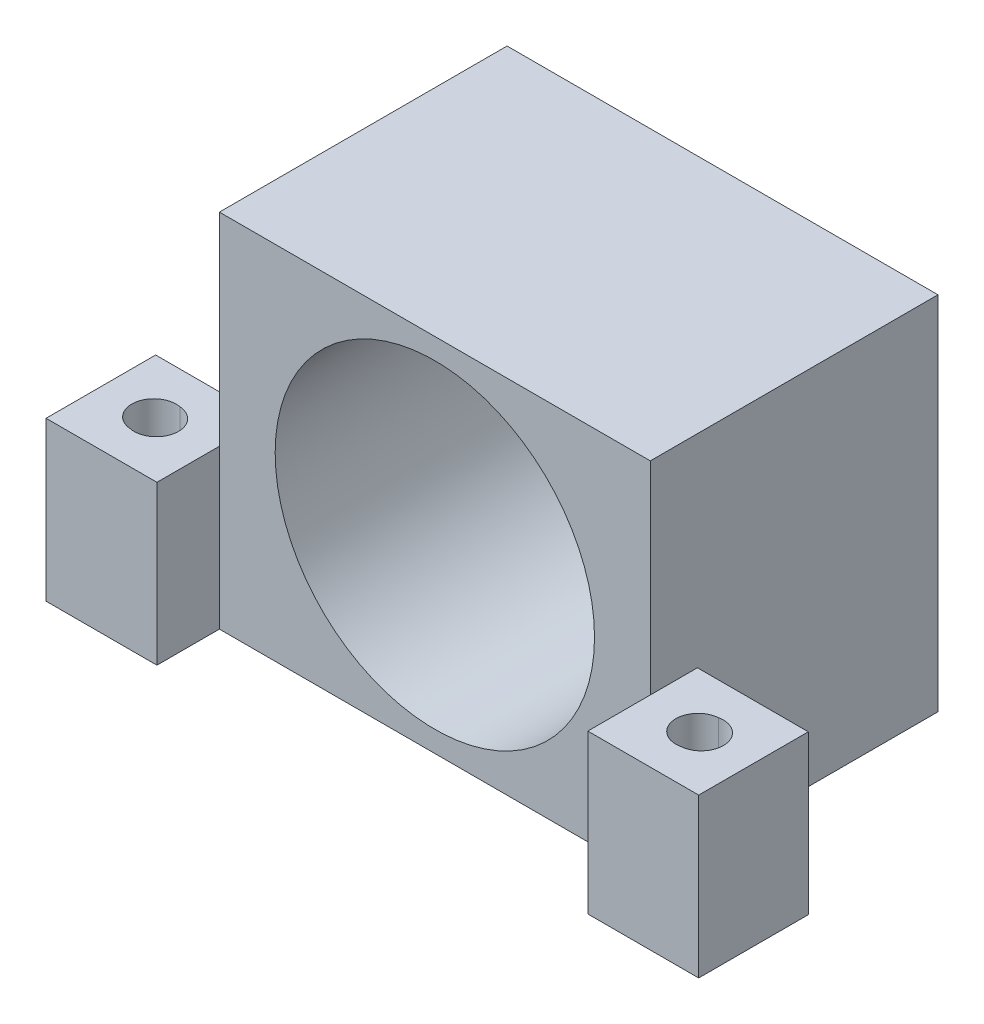
from build123d import *

# Parameters (mm, degrees)
SKETCH1_W                = 34
SKETCH1_H                = 28.5
BOSS_EXTRUDE1_DEPTH      = 22.7
SKETCH3_R                = 12.6
CUT_EXTRUDE1_DEPTH       = 19
SKETCH5_R                = 1.625
SKETCH5_R_2              = 3.75
CUT_EXTRUDE2_DEPTH       = 30.207233693
BOSS_EXTRUDE2_DEPTH      = 4.93
BOSS_EXTRUDE2_DEPTH_BACK = 3.72
SKETCH7_W                = 8.75
SKETCH7_H                = 12.5
SKETCH8_R                = 1.75
CUT_EXTRUDE3_DEPTH       = 42.018037496
SKETCH9_R                = 3.25
CUT_EXTRUDE4_DEPTH       = 3.175
SKETCH14_R               = 1.75
CUT_EXTRUDE8_DEPTH       = 50


with BuildPart() as part:
    # Sketch1 → Boss-Extrude1 (new body)
    with BuildSketch(Plane.XY):
        Rectangle(SKETCH1_W, SKETCH1_H)
    extrude(amount=BOSS_EXTRUDE1_DEPTH)

    # Sketch3 → Cut-Extrude1 (cut)
    with BuildSketch(Plane.XY.offset(22.7)):
        Circle(SKETCH3_R)
    extrude(amount=-CUT_EXTRUDE1_DEPTH, mode=Mode.SUBTRACT)

    # Sketch5 → Cut-Extrude2 (cut, through all)
    with BuildSketch(Plane.XY.offset(3.7)):
        with Locations((6.01040764, 6.01040764)):
            Circle(SKETCH5_R)
        with Locations((-6.01040764, 6.01040764)):
            Circle(SKETCH5_R)
        with Locations((6.01040764, -6.01040764)):
            Circle(SKETCH5_R)
        with Locations((-6.01040764, -6.01040764)):
            Circle(SKETCH5_R)
        Circle(SKETCH5_R_2)
    extrude(amount=-CUT_EXTRUDE2_DEPTH, mode=Mode.SUBTRACT)

    # Sketch7 → Boss-Extrude2 (add, two sides: drawn at the far end of the back side and taken through both)
    with BuildSketch(Plane.XY.offset(22.7).offset(-BOSS_EXTRUDE2_DEPTH_BACK)):
        with Locations((-21.375, -8)):
            Rectangle(SKETCH7_W, SKETCH7_H)
        with Locations((21.375, -8)):
            Rectangle(SKETCH7_W, SKETCH7_H)
    extrude(amount=BOSS_EXTRUDE2_DEPTH + BOSS_EXTRUDE2_DEPTH_BACK)

    # Sketch8 → Cut-Extrude3 (cut, through all)
    with BuildSketch(Plane(origin=(0, -1.75, 0), x_dir=(1, 0, 0), z_dir=(0, 1, 0))):
        with Locations(Location((21.375, -23.305, 0), (0, 0, 180))):
            Circle(SKETCH8_R)
        with Locations(Location((-21.375, -23.305, 0), (0, 0, 180))):
            Circle(SKETCH8_R)
    extrude(amount=-CUT_EXTRUDE3_DEPTH, mode=Mode.SUBTRACT)

    # Sketch9 → Cut-Extrude4 (cut)
    with BuildSketch(Plane.XZ.offset(14.25)):
        with Locations((-21.375, 23.305)):
            Circle(SKETCH9_R)
        with Locations((21.375, 23.305)):
            Circle(SKETCH9_R)
    extrude(amount=-CUT_EXTRUDE4_DEPTH, mode=Mode.SUBTRACT)

    # Cut-Extrude5 cone 1 section (through the dimple's axis) → Cut-Extrude5 (revolve, cut)
    with BuildSketch(Plane(origin=(-6.01040764, 6.01040764, 0), x_dir=(0, 1, 0), z_dir=(1, 0, 0))):
        Polygon((0, 0), (2.8, 0), (0, 2.8), align=None)
    revolve(axis=Axis((-6.01040764, 6.01040764, 0), (0, 0, 1)), mode=Mode.SUBTRACT)

    # Cut-Extrude5 cone 2 section (through the dimple's axis) → Cut-Extrude5 cone 2 (revolve, cut)
    with BuildSketch(Plane(origin=(-6.01040764, -6.01040764, 0), x_dir=(0, 1, 0), z_dir=(1, 0, 0))):
        Polygon((0, 0), (2.8, 0), (0, 2.8), align=None)
    revolve(axis=Axis((-6.01040764, -6.01040764, 0), (0, 0, 1)), mode=Mode.SUBTRACT)

    # Cut-Extrude5 cone 3 section (through the dimple's axis) → Cut-Extrude5 cone 3 (revolve, cut)
    with BuildSketch(Plane(origin=(6.01040764, -6.01040764, 0), x_dir=(0, 1, 0), z_dir=(1, 0, 0))):
        Polygon((0, 0), (2.8, 0), (0, 2.8), align=None)
    revolve(axis=Axis((6.01040764, -6.01040764, 0), (0, 0, 1)), mode=Mode.SUBTRACT)

    # Cut-Extrude5 cone 4 section (through the dimple's axis) → Cut-Extrude5 cone 4 (revolve, cut)
    with BuildSketch(Plane(origin=(6.01040764, 6.01040764, 0), x_dir=(0, 1, 0), z_dir=(1, 0, 0))):
        Polygon((0, 0), (2.8, 0), (0, 2.8), align=None)
    revolve(axis=Axis((6.01040764, 6.01040764, 0), (0, 0, 1)), mode=Mode.SUBTRACT)

    # Sketch14 → Cut-Extrude8 (cut)
    with BuildSketch(Plane(origin=(132.323959999, 1.25, 25.756345109), x_dir=(1, 0, 0), z_dir=(0, 1, 0))):
        with Locations((-110.733959999, 2.481345109)):
            Circle(SKETCH14_R)
        with Locations((-153.913959999, 2.481345109)):
            Circle(SKETCH14_R)
    extrude(amount=-CUT_EXTRUDE8_DEPTH, mode=Mode.SUBTRACT)


solid = part.part
